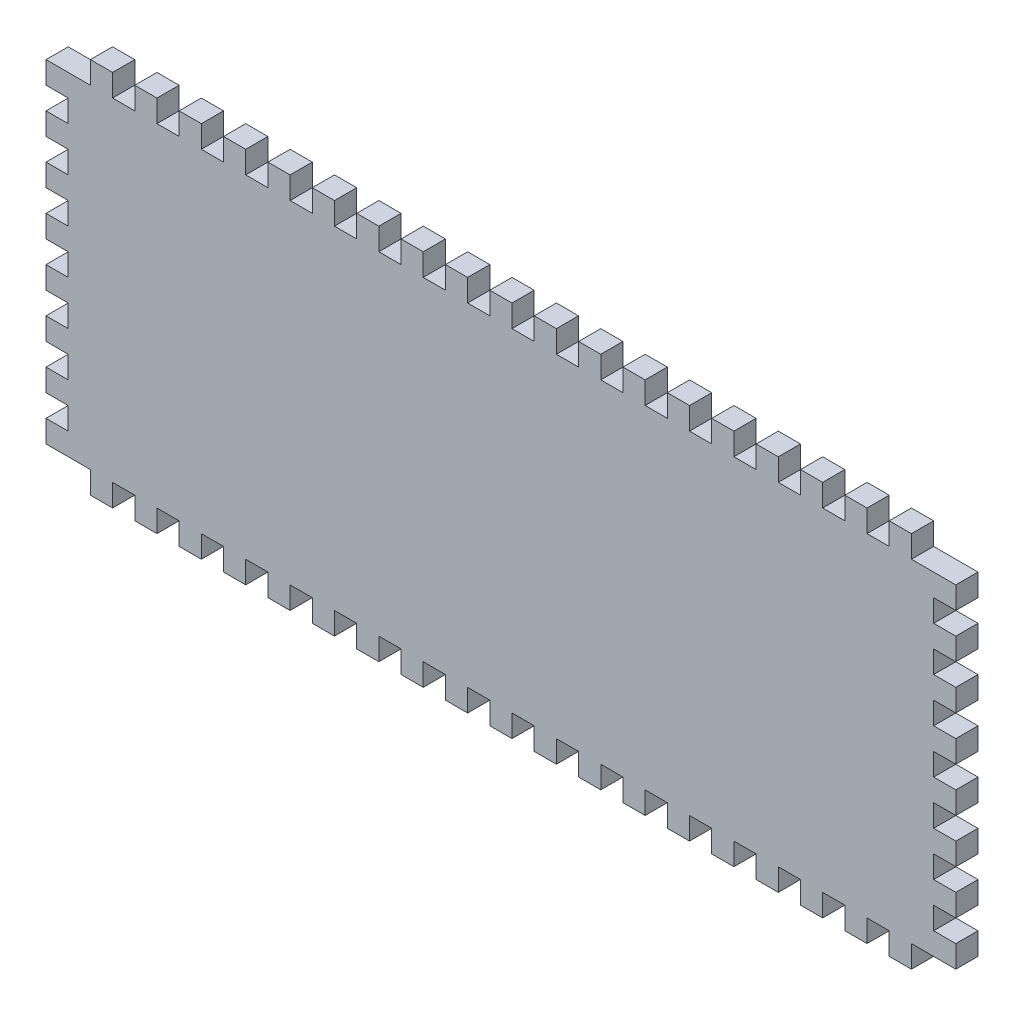
from build123d import *

# Parameters (mm, degrees)
SKETCH1_W                = 260.35
SKETCH1_H                = 107.95
BOSS_EXTRUDE1_DEPTH      = 6.35
SKETCH3_W                = 6.35
SKETCH3_H                = 6.35
CUT_EXTRUDE1_DEPTH       = 7.35
LPATTERN1_COUNT          = 20
LPATTERN1_PITCH          = 12.7
MIRROR1_COPY_1_SKETCH_W  = 6.35
MIRROR1_COPY_1_SKETCH_H  = 6.35
MIRROR1_COPY_1_DEPTH     = 7.35
MIRROR1_COPY_2_SKETCH_W  = 6.35
MIRROR1_COPY_2_SKETCH_H  = 6.35
MIRROR1_COPY_2_DEPTH     = 7.35
MIRROR1_COPY_3_SKETCH_W  = 6.35
MIRROR1_COPY_3_SKETCH_H  = 6.35
MIRROR1_COPY_3_DEPTH     = 7.35
MIRROR1_COPY_4_SKETCH_W  = 6.35
MIRROR1_COPY_4_SKETCH_H  = 6.35
MIRROR1_COPY_4_DEPTH     = 7.35
MIRROR1_COPY_5_SKETCH_W  = 6.35
MIRROR1_COPY_5_SKETCH_H  = 6.35
MIRROR1_COPY_5_DEPTH     = 7.35
MIRROR1_COPY_6_SKETCH_W  = 6.35
MIRROR1_COPY_6_SKETCH_H  = 6.35
MIRROR1_COPY_6_DEPTH     = 7.35
MIRROR1_COPY_7_SKETCH_W  = 6.35
MIRROR1_COPY_7_SKETCH_H  = 6.35
MIRROR1_COPY_7_DEPTH     = 7.35
MIRROR1_COPY_8_SKETCH_W  = 6.35
MIRROR1_COPY_8_SKETCH_H  = 6.35
MIRROR1_COPY_8_DEPTH     = 7.35
MIRROR1_COPY_9_SKETCH_W  = 6.35
MIRROR1_COPY_9_SKETCH_H  = 6.35
MIRROR1_COPY_9_DEPTH     = 7.35
MIRROR1_COPY_10_SKETCH_W = 6.35
MIRROR1_COPY_10_SKETCH_H = 6.35
MIRROR1_COPY_10_DEPTH    = 7.35
MIRROR1_COPY_11_SKETCH_W = 6.35
MIRROR1_COPY_11_SKETCH_H = 6.35
MIRROR1_COPY_11_DEPTH    = 7.35
MIRROR1_COPY_12_SKETCH_W = 6.35
MIRROR1_COPY_12_SKETCH_H = 6.35
MIRROR1_COPY_12_DEPTH    = 7.35
MIRROR1_COPY_13_SKETCH_W = 6.35
MIRROR1_COPY_13_SKETCH_H = 6.35
MIRROR1_COPY_13_DEPTH    = 7.35
MIRROR1_COPY_14_SKETCH_W = 6.35
MIRROR1_COPY_14_SKETCH_H = 6.35
MIRROR1_COPY_14_DEPTH    = 7.35
MIRROR1_COPY_15_SKETCH_W = 6.35
MIRROR1_COPY_15_SKETCH_H = 6.35
MIRROR1_COPY_15_DEPTH    = 7.35
MIRROR1_COPY_16_SKETCH_W = 6.35
MIRROR1_COPY_16_SKETCH_H = 6.35
MIRROR1_COPY_16_DEPTH    = 7.35
MIRROR1_COPY_17_SKETCH_W = 6.35
MIRROR1_COPY_17_SKETCH_H = 6.35
MIRROR1_COPY_17_DEPTH    = 7.35
MIRROR1_COPY_18_SKETCH_W = 6.35
MIRROR1_COPY_18_SKETCH_H = 6.35
MIRROR1_COPY_18_DEPTH    = 7.35
MIRROR1_COPY_19_SKETCH_W = 6.35
MIRROR1_COPY_19_SKETCH_H = 6.35
MIRROR1_COPY_19_DEPTH    = 7.35
SKETCH4_W                = 6.35
SKETCH4_H                = 6.35
CUT_EXTRUDE2_DEPTH       = 7.35
LPATTERN3_COUNT          = 9
LPATTERN3_PITCH          = 12.7
MIRROR2_COPY_1_SKETCH_W  = 6.35
MIRROR2_COPY_1_SKETCH_H  = 6.35
MIRROR2_COPY_1_DEPTH     = 7.35
MIRROR2_COPY_2_SKETCH_W  = 6.35
MIRROR2_COPY_2_SKETCH_H  = 6.35
MIRROR2_COPY_2_DEPTH     = 7.35
MIRROR2_COPY_3_SKETCH_W  = 6.35
MIRROR2_COPY_3_SKETCH_H  = 6.35
MIRROR2_COPY_3_DEPTH     = 7.35
MIRROR2_COPY_4_SKETCH_W  = 6.35
MIRROR2_COPY_4_SKETCH_H  = 6.35
MIRROR2_COPY_4_DEPTH     = 7.35
MIRROR2_COPY_5_SKETCH_W  = 6.35
MIRROR2_COPY_5_SKETCH_H  = 6.35
MIRROR2_COPY_5_DEPTH     = 7.35
MIRROR2_COPY_6_SKETCH_W  = 6.35
MIRROR2_COPY_6_SKETCH_H  = 6.35
MIRROR2_COPY_6_DEPTH     = 7.35
MIRROR2_COPY_7_SKETCH_W  = 6.35
MIRROR2_COPY_7_SKETCH_H  = 6.35
MIRROR2_COPY_7_DEPTH     = 7.35
MIRROR2_COPY_8_SKETCH_W  = 6.35
MIRROR2_COPY_8_SKETCH_H  = 6.35
MIRROR2_COPY_8_DEPTH     = 7.35


with BuildPart() as part:
    # Sketch1 → Boss-Extrude1 (new body)
    with BuildSketch(Plane.XY):
        Rectangle(SKETCH1_W, SKETCH1_H)
    extrude(amount=BOSS_EXTRUDE1_DEPTH)

    # Sketch3 → Cut-Extrude1 (cut, through all)
    with BuildSketch(Plane.XY.offset(6.35)):
        with Locations((-120.65, -50.8)):
            Rectangle(SKETCH3_W, SKETCH3_H)
    cut_extrude1 = extrude(amount=-CUT_EXTRUDE1_DEPTH, mode=Mode.SUBTRACT)

    # LPattern1: Cut-Extrude1 ×20
    with Locations(*[(i * LPATTERN1_PITCH, 0, 0) for i in range(1, LPATTERN1_COUNT)]):
        add(cut_extrude1, mode=Mode.SUBTRACT)

    # Mirror1: Cut-Extrude1 across plane
    add(cut_extrude1.mirror(Plane.ZX), mode=Mode.SUBTRACT)

    # Mirror1 copy 1 sketch → Mirror1 copy 1 (cut, through all)
    with BuildSketch(Plane(origin=(12.7, 0, 6.35), x_dir=(1, 0, 0), z_dir=(0, 0, 1))):
        with Locations((-120.65, 50.8)):
            Rectangle(MIRROR1_COPY_1_SKETCH_W, MIRROR1_COPY_1_SKETCH_H)
    extrude(amount=-MIRROR1_COPY_1_DEPTH, mode=Mode.SUBTRACT)

    # Mirror1 copy 2 sketch → Mirror1 copy 2 (cut, through all)
    with BuildSketch(Plane(origin=(25.4, 0, 6.35), x_dir=(1, 0, 0), z_dir=(0, 0, 1))):
        with Locations((-120.65, 50.8)):
            Rectangle(MIRROR1_COPY_2_SKETCH_W, MIRROR1_COPY_2_SKETCH_H)
    extrude(amount=-MIRROR1_COPY_2_DEPTH, mode=Mode.SUBTRACT)

    # Mirror1 copy 3 sketch → Mirror1 copy 3 (cut, through all)
    with BuildSketch(Plane(origin=(38.1, 0, 6.35), x_dir=(1, 0, 0), z_dir=(0, 0, 1))):
        with Locations((-120.65, 50.8)):
            Rectangle(MIRROR1_COPY_3_SKETCH_W, MIRROR1_COPY_3_SKETCH_H)
    extrude(amount=-MIRROR1_COPY_3_DEPTH, mode=Mode.SUBTRACT)

    # Mirror1 copy 4 sketch → Mirror1 copy 4 (cut, through all)
    with BuildSketch(Plane(origin=(50.8, 0, 6.35), x_dir=(1, 0, 0), z_dir=(0, 0, 1))):
        with Locations((-120.65, 50.8)):
            Rectangle(MIRROR1_COPY_4_SKETCH_W, MIRROR1_COPY_4_SKETCH_H)
    extrude(amount=-MIRROR1_COPY_4_DEPTH, mode=Mode.SUBTRACT)

    # Mirror1 copy 5 sketch → Mirror1 copy 5 (cut, through all)
    with BuildSketch(Plane(origin=(63.5, 0, 6.35), x_dir=(1, 0, 0), z_dir=(0, 0, 1))):
        with Locations((-120.65, 50.8)):
            Rectangle(MIRROR1_COPY_5_SKETCH_W, MIRROR1_COPY_5_SKETCH_H)
    extrude(amount=-MIRROR1_COPY_5_DEPTH, mode=Mode.SUBTRACT)

    # Mirror1 copy 6 sketch → Mirror1 copy 6 (cut, through all)
    with BuildSketch(Plane(origin=(76.2, 0, 6.35), x_dir=(1, 0, 0), z_dir=(0, 0, 1))):
        with Locations((-120.65, 50.8)):
            Rectangle(MIRROR1_COPY_6_SKETCH_W, MIRROR1_COPY_6_SKETCH_H)
    extrude(amount=-MIRROR1_COPY_6_DEPTH, mode=Mode.SUBTRACT)

    # Mirror1 copy 7 sketch → Mirror1 copy 7 (cut, through all)
    with BuildSketch(Plane(origin=(88.9, 0, 6.35), x_dir=(1, 0, 0), z_dir=(0, 0, 1))):
        with Locations((-120.65, 50.8)):
            Rectangle(MIRROR1_COPY_7_SKETCH_W, MIRROR1_COPY_7_SKETCH_H)
    extrude(amount=-MIRROR1_COPY_7_DEPTH, mode=Mode.SUBTRACT)

    # Mirror1 copy 8 sketch → Mirror1 copy 8 (cut, through all)
    with BuildSketch(Plane(origin=(101.6, 0, 6.35), x_dir=(1, 0, 0), z_dir=(0, 0, 1))):
        with Locations((-120.65, 50.8)):
            Rectangle(MIRROR1_COPY_8_SKETCH_W, MIRROR1_COPY_8_SKETCH_H)
    extrude(amount=-MIRROR1_COPY_8_DEPTH, mode=Mode.SUBTRACT)

    # Mirror1 copy 9 sketch → Mirror1 copy 9 (cut, through all)
    with BuildSketch(Plane(origin=(114.3, 0, 6.35), x_dir=(1, 0, 0), z_dir=(0, 0, 1))):
        with Locations((-120.65, 50.8)):
            Rectangle(MIRROR1_COPY_9_SKETCH_W, MIRROR1_COPY_9_SKETCH_H)
    extrude(amount=-MIRROR1_COPY_9_DEPTH, mode=Mode.SUBTRACT)

    # Mirror1 copy 10 sketch → Mirror1 copy 10 (cut, through all)
    with BuildSketch(Plane(origin=(127, 0, 6.35), x_dir=(1, 0, 0), z_dir=(0, 0, 1))):
        with Locations((-120.65, 50.8)):
            Rectangle(MIRROR1_COPY_10_SKETCH_W, MIRROR1_COPY_10_SKETCH_H)
    extrude(amount=-MIRROR1_COPY_10_DEPTH, mode=Mode.SUBTRACT)

    # Mirror1 copy 11 sketch → Mirror1 copy 11 (cut, through all)
    with BuildSketch(Plane(origin=(139.7, 0, 6.35), x_dir=(1, 0, 0), z_dir=(0, 0, 1))):
        with Locations((-120.65, 50.8)):
            Rectangle(MIRROR1_COPY_11_SKETCH_W, MIRROR1_COPY_11_SKETCH_H)
    extrude(amount=-MIRROR1_COPY_11_DEPTH, mode=Mode.SUBTRACT)

    # Mirror1 copy 12 sketch → Mirror1 copy 12 (cut, through all)
    with BuildSketch(Plane(origin=(152.4, 0, 6.35), x_dir=(1, 0, 0), z_dir=(0, 0, 1))):
        with Locations((-120.65, 50.8)):
            Rectangle(MIRROR1_COPY_12_SKETCH_W, MIRROR1_COPY_12_SKETCH_H)
    extrude(amount=-MIRROR1_COPY_12_DEPTH, mode=Mode.SUBTRACT)

    # Mirror1 copy 13 sketch → Mirror1 copy 13 (cut, through all)
    with BuildSketch(Plane(origin=(165.1, 0, 6.35), x_dir=(1, 0, 0), z_dir=(0, 0, 1))):
        with Locations((-120.65, 50.8)):
            Rectangle(MIRROR1_COPY_13_SKETCH_W, MIRROR1_COPY_13_SKETCH_H)
    extrude(amount=-MIRROR1_COPY_13_DEPTH, mode=Mode.SUBTRACT)

    # Mirror1 copy 14 sketch → Mirror1 copy 14 (cut, through all)
    with BuildSketch(Plane(origin=(177.8, 0, 6.35), x_dir=(1, 0, 0), z_dir=(0, 0, 1))):
        with Locations((-120.65, 50.8)):
            Rectangle(MIRROR1_COPY_14_SKETCH_W, MIRROR1_COPY_14_SKETCH_H)
    extrude(amount=-MIRROR1_COPY_14_DEPTH, mode=Mode.SUBTRACT)

    # Mirror1 copy 15 sketch → Mirror1 copy 15 (cut, through all)
    with BuildSketch(Plane(origin=(190.5, 0, 6.35), x_dir=(1, 0, 0), z_dir=(0, 0, 1))):
        with Locations((-120.65, 50.8)):
            Rectangle(MIRROR1_COPY_15_SKETCH_W, MIRROR1_COPY_15_SKETCH_H)
    extrude(amount=-MIRROR1_COPY_15_DEPTH, mode=Mode.SUBTRACT)

    # Mirror1 copy 16 sketch → Mirror1 copy 16 (cut, through all)
    with BuildSketch(Plane(origin=(203.2, 0, 6.35), x_dir=(1, 0, 0), z_dir=(0, 0, 1))):
        with Locations((-120.65, 50.8)):
            Rectangle(MIRROR1_COPY_16_SKETCH_W, MIRROR1_COPY_16_SKETCH_H)
    extrude(amount=-MIRROR1_COPY_16_DEPTH, mode=Mode.SUBTRACT)

    # Mirror1 copy 17 sketch → Mirror1 copy 17 (cut, through all)
    with BuildSketch(Plane(origin=(215.9, 0, 6.35), x_dir=(1, 0, 0), z_dir=(0, 0, 1))):
        with Locations((-120.65, 50.8)):
            Rectangle(MIRROR1_COPY_17_SKETCH_W, MIRROR1_COPY_17_SKETCH_H)
    extrude(amount=-MIRROR1_COPY_17_DEPTH, mode=Mode.SUBTRACT)

    # Mirror1 copy 18 sketch → Mirror1 copy 18 (cut, through all)
    with BuildSketch(Plane(origin=(228.6, 0, 6.35), x_dir=(1, 0, 0), z_dir=(0, 0, 1))):
        with Locations((-120.65, 50.8)):
            Rectangle(MIRROR1_COPY_18_SKETCH_W, MIRROR1_COPY_18_SKETCH_H)
    extrude(amount=-MIRROR1_COPY_18_DEPTH, mode=Mode.SUBTRACT)

    # Mirror1 copy 19 sketch → Mirror1 copy 19 (cut, through all)
    with BuildSketch(Plane(origin=(241.3, 0, 6.35), x_dir=(1, 0, 0), z_dir=(0, 0, 1))):
        with Locations((-120.65, 50.8)):
            Rectangle(MIRROR1_COPY_19_SKETCH_W, MIRROR1_COPY_19_SKETCH_H)
    extrude(amount=-MIRROR1_COPY_19_DEPTH, mode=Mode.SUBTRACT)

    # Sketch4 → Cut-Extrude2 (cut, through all)
    with BuildSketch(Plane.XY.offset(6.35)):
        with Locations((-127, -50.8)):
            Rectangle(SKETCH4_W, SKETCH4_H)
    cut_extrude2 = extrude(amount=-CUT_EXTRUDE2_DEPTH, mode=Mode.SUBTRACT)

    # LPattern3: Cut-Extrude2 ×9
    with Locations(*[(0, i * LPATTERN3_PITCH, 0) for i in range(1, LPATTERN3_COUNT)]):
        add(cut_extrude2, mode=Mode.SUBTRACT)

    # Mirror2: Cut-Extrude2 across plane
    add(cut_extrude2.mirror(Plane(origin=(0, 0, 0), x_dir=(0, 0, 1), z_dir=(1, 0, 0))), mode=Mode.SUBTRACT)

    # Mirror2 copy 1 sketch → Mirror2 copy 1 (cut, through all)
    with BuildSketch(Plane(origin=(0, 12.7, 6.35), x_dir=(-1, 0, 0), z_dir=(0, 0, 1))):
        with Locations((-127, 50.8)):
            Rectangle(MIRROR2_COPY_1_SKETCH_W, MIRROR2_COPY_1_SKETCH_H)
    extrude(amount=-MIRROR2_COPY_1_DEPTH, mode=Mode.SUBTRACT)

    # Mirror2 copy 2 sketch → Mirror2 copy 2 (cut, through all)
    with BuildSketch(Plane(origin=(0, 25.4, 6.35), x_dir=(-1, 0, 0), z_dir=(0, 0, 1))):
        with Locations((-127, 50.8)):
            Rectangle(MIRROR2_COPY_2_SKETCH_W, MIRROR2_COPY_2_SKETCH_H)
    extrude(amount=-MIRROR2_COPY_2_DEPTH, mode=Mode.SUBTRACT)

    # Mirror2 copy 3 sketch → Mirror2 copy 3 (cut, through all)
    with BuildSketch(Plane(origin=(0, 38.1, 6.35), x_dir=(-1, 0, 0), z_dir=(0, 0, 1))):
        with Locations((-127, 50.8)):
            Rectangle(MIRROR2_COPY_3_SKETCH_W, MIRROR2_COPY_3_SKETCH_H)
    extrude(amount=-MIRROR2_COPY_3_DEPTH, mode=Mode.SUBTRACT)

    # Mirror2 copy 4 sketch → Mirror2 copy 4 (cut, through all)
    with BuildSketch(Plane(origin=(0, 50.8, 6.35), x_dir=(-1, 0, 0), z_dir=(0, 0, 1))):
        with Locations((-127, 50.8)):
            Rectangle(MIRROR2_COPY_4_SKETCH_W, MIRROR2_COPY_4_SKETCH_H)
    extrude(amount=-MIRROR2_COPY_4_DEPTH, mode=Mode.SUBTRACT)

    # Mirror2 copy 5 sketch → Mirror2 copy 5 (cut, through all)
    with BuildSketch(Plane(origin=(0, 63.5, 6.35), x_dir=(-1, 0, 0), z_dir=(0, 0, 1))):
        with Locations((-127, 50.8)):
            Rectangle(MIRROR2_COPY_5_SKETCH_W, MIRROR2_COPY_5_SKETCH_H)
    extrude(amount=-MIRROR2_COPY_5_DEPTH, mode=Mode.SUBTRACT)

    # Mirror2 copy 6 sketch → Mirror2 copy 6 (cut, through all)
    with BuildSketch(Plane(origin=(0, 76.2, 6.35), x_dir=(-1, 0, 0), z_dir=(0, 0, 1))):
        with Locations((-127, 50.8)):
            Rectangle(MIRROR2_COPY_6_SKETCH_W, MIRROR2_COPY_6_SKETCH_H)
    extrude(amount=-MIRROR2_COPY_6_DEPTH, mode=Mode.SUBTRACT)

    # Mirror2 copy 7 sketch → Mirror2 copy 7 (cut, through all)
    with BuildSketch(Plane(origin=(0, 88.9, 6.35), x_dir=(-1, 0, 0), z_dir=(0, 0, 1))):
        with Locations((-127, 50.8)):
            Rectangle(MIRROR2_COPY_7_SKETCH_W, MIRROR2_COPY_7_SKETCH_H)
    extrude(amount=-MIRROR2_COPY_7_DEPTH, mode=Mode.SUBTRACT)

    # Mirror2 copy 8 sketch → Mirror2 copy 8 (cut, through all)
    with BuildSketch(Plane(origin=(0, 101.6, 6.35), x_dir=(-1, 0, 0), z_dir=(0, 0, 1))):
        with Locations((-127, 50.8)):
            Rectangle(MIRROR2_COPY_8_SKETCH_W, MIRROR2_COPY_8_SKETCH_H)
    extrude(amount=-MIRROR2_COPY_8_DEPTH, mode=Mode.SUBTRACT)


solid = part.part
